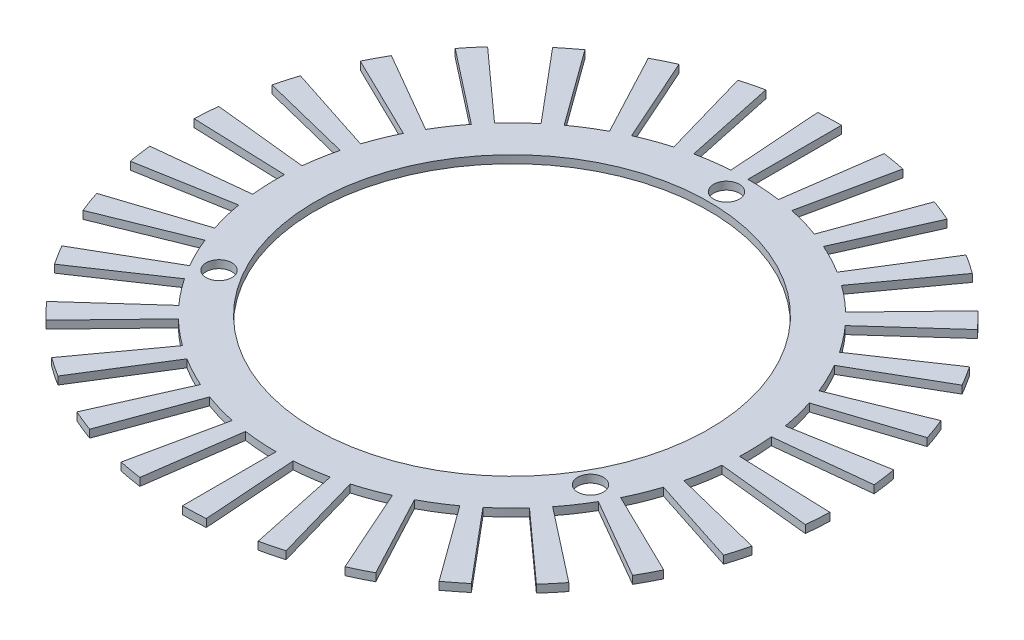
from build123d import *

# Parameters (mm, degrees)
SKETCH1_R           = 30.25
SKETCH1_R_2         = 25.25
EXTRUDE_THIN1_DEPTH = 1
SKETCH2_R           = 1.65
CUT_EXTRUDE3_DEPTH  = 10
BOSS_EXTRUDE1_DEPTH = 1


with BuildPart() as part:
    # Sketch1 → Extrude-Thin1 (new body)
    with BuildSketch(Plane(origin=(0, 0, 0), x_dir=(1, 0, 0), z_dir=(0, 1, 0))):
        Circle(SKETCH1_R)
        Circle(SKETCH1_R_2, mode=Mode.SUBTRACT)
    extrude(amount=-EXTRUDE_THIN1_DEPTH)

    # Sketch2 → Cut-Extrude3 (cut)
    with BuildSketch(Plane(origin=(0, 0, 0), x_dir=(1, 0, 0), z_dir=(0, 1, 0))):
        with Locations((0, 27.5)):
            Circle(SKETCH2_R)
        with Locations((23.815698604, -13.75)):
            Circle(SKETCH2_R)
        with Locations((-23.815698604, -13.75)):
            Circle(SKETCH2_R)
    extrude(amount=-CUT_EXTRUDE3_DEPTH, mode=Mode.SUBTRACT)

    # Sketch5 → Boss-Extrude1 (add)
    with BuildSketch(Plane.XZ.offset(1)):
        with BuildLine():
            Line((0, 42.25), (0, 30.25))
            ThreePointArc((0, 30.25), (1.055709775, 30.231572517), (2.110133331, 30.17631252))
            Line((2.110133331, 30.17631252), (2.947211016, 42.147081123))
            ThreePointArc((2.947211016, 42.147081123), (1.474503736, 42.224262442), (0, 42.25))
        make_face()
        with BuildLine():
            Line((8.784268937, 41.326736131), (6.289328647, 29.588964922))
            ThreePointArc((6.289328647, 29.588964922), (7.318137342, 29.35144572), (8.338030013, 29.078166302))
            Line((8.338030013, 29.078166302), (11.645678283, 40.613306653))
            ThreePointArc((11.645678283, 40.613306653), (10.221200089, 40.994994435), (8.784268937, 41.326736131))
        make_face()
        with BuildLine():
            Line((17.18462317, 38.597295585), (12.303783453, 27.634750094))
            ThreePointArc((12.303783453, 27.634750094), (13.26072719, 27.188519901), (14.201514774, 26.709164684))
            Line((14.201514774, 26.709164684), (19.835173528, 37.304535798))
            ThreePointArc((19.835173528, 37.304535798), (18.521180952, 37.974048456), (17.18462317, 38.597295585))
        make_face()
        with BuildLine():
            Line((24.833926909, 34.180968012), (17.780503882, 24.47276408))
            ThreePointArc((17.780503882, 24.47276408), (18.623759629, 23.837325297), (19.444325193, 23.172844404))
            Line((19.444325193, 23.172844404), (27.157776509, 32.365377722))
            ThreePointArc((27.157776509, 32.365377722), (26.011697333, 33.29345434), (24.833926909, 34.180968012))
        make_face()
        with BuildLine():
            Line((31.397868876, 28.270768119), (22.480130971, 20.241200842))
            ThreePointArc((22.480130971, 20.241200842), (23.172844404, 19.444325193), (23.837325297, 18.623759629))
            Line((23.837325297, 18.623759629), (33.29345434, 26.011697333))
            ThreePointArc((33.29345434, 26.011697333), (32.365377722, 27.157776509), (31.397868876, 28.270768119))
        make_face()
        with BuildLine():
            Line((36.58957331, 21.125), (26.197268464, 15.125))
            ThreePointArc((26.197268464, 15.125), (26.709164684, 14.201514774), (27.188519901, 13.26072719))
            Line((27.188519901, 13.26072719), (37.974048456, 18.521180952))
            ThreePointArc((37.974048456, 18.521180952), (37.304535798, 19.835173528), (36.58957331, 21.125))
        make_face()
        with BuildLine():
            Line((40.182137813, 13.055968012), (28.769459618, 9.34776408))
            ThreePointArc((28.769459618, 9.34776408), (29.078166302, 8.338030013), (29.35144572, 7.318137342))
            Line((29.35144572, 7.318137342), (40.994994435, 10.221200089))
            ThreePointArc((40.994994435, 10.221200089), (40.613306653, 11.645678283), (40.182137813, 13.055968012))
        make_face()
        with BuildLine():
            Line((42.018550079, 4.416327573), (30.084287335, 3.161986014))
            ThreePointArc((30.084287335, 3.161986014), (30.17631252, 2.110133331), (30.231572517, 1.055709775))
            Line((30.231572517, 1.055709775), (42.224262442, 1.474503736))
            ThreePointArc((42.224262442, 1.474503736), (42.147081123, 2.947211016), (42.018550079, 4.416327573))
        make_face()
        with BuildLine():
            Line((42.018550079, -4.416327573), (30.084287335, -3.161986014))
            ThreePointArc((30.084287335, -3.161986014), (29.955609079, -4.209986304), (29.790434529, -5.252857374))
            Line((29.790434529, -5.252857374), (41.608127565, -7.336635506))
            ThreePointArc((41.608127565, -7.336635506), (41.838825904, -5.880063516), (42.018550079, -4.416327573))
        make_face()
        with BuildLine():
            Line((40.182137813, -13.055968012), (28.769459618, -9.34776408))
            ThreePointArc((28.769459618, -9.34776408), (28.425701779, -10.346109336), (28.047311601, -11.331849451))
            Line((28.047311601, -11.331849451), (39.173517855, -15.827128572))
            ThreePointArc((39.173517855, -15.827128572), (39.702013228, -14.450351056), (40.182137813, -13.055968012))
        make_face()
        with BuildLine():
            Line((36.58957331, -21.125), (26.197268464, -15.125))
            ThreePointArc((26.197268464, -15.125), (25.653454909, -16.030057743), (25.07838657, -16.91558533))
            Line((25.07838657, -16.91558533), (35.02683744, -23.625900172))
            ThreePointArc((35.02683744, -23.625900172), (35.830032063, -22.389088914), (36.58957331, -21.125))
        make_face()
        with BuildLine():
            Line((31.397868876, -28.270768119), (22.480130971, -20.241200842))
            ThreePointArc((22.480130971, -20.241200842), (21.76002896, -21.013415706), (21.013415706, -21.76002896))
            Line((21.013415706, -21.76002896), (29.349316152, -30.392106564))
            ThreePointArc((29.349316152, -30.392106564), (30.392106564, -29.349316152), (31.397868876, -28.270768119))
        make_face()
        with BuildLine():
            Line((24.833926909, -34.180968012), (17.780503882, -24.47276408))
            ThreePointArc((17.780503882, -24.47276408), (16.91558533, -25.07838657), (16.030057743, -25.653454909))
            Line((16.030057743, -25.653454909), (22.389088914, -35.830032063))
            ThreePointArc((22.389088914, -35.830032063), (23.625900172, -35.02683744), (24.833926909, -34.180968012))
        make_face()
        with BuildLine():
            Line((17.18462317, -38.597295585), (12.303783453, -27.634750094))
            ThreePointArc((12.303783453, -27.634750094), (11.331849451, -28.047311601), (10.346109336, -28.425701779))
            Line((10.346109336, -28.425701779), (14.450351056, -39.702013228))
            ThreePointArc((14.450351056, -39.702013228), (15.827128572, -39.173517855), (17.18462317, -38.597295585))
        make_face()
        with BuildLine():
            Line((8.784268937, -41.326736131), (6.289328647, -29.588964922))
            ThreePointArc((6.289328647, -29.588964922), (5.252857374, -29.790434529), (4.209986304, -29.955609079))
            Line((4.209986304, -29.955609079), (5.880063516, -41.838825904))
            ThreePointArc((5.880063516, -41.838825904), (7.336635506, -41.608127565), (8.784268937, -41.326736131))
        make_face()
        with BuildLine():
            Line((0, -42.25), (0, -30.25))
            ThreePointArc((0, -30.25), (-1.055709775, -30.231572517), (-2.110133331, -30.17631252))
            Line((-2.110133331, -30.17631252), (-2.947211016, -42.147081123))
            ThreePointArc((-2.947211016, -42.147081123), (-1.474503736, -42.224262442), (0, -42.25))
        make_face()
        with BuildLine():
            Line((-8.784268937, -41.326736131), (-6.289328647, -29.588964922))
            ThreePointArc((-6.289328647, -29.588964922), (-7.318137342, -29.35144572), (-8.338030013, -29.078166302))
            Line((-8.338030013, -29.078166302), (-11.645678283, -40.613306653))
            ThreePointArc((-11.645678283, -40.613306653), (-10.221200089, -40.994994435), (-8.784268937, -41.326736131))
        make_face()
        with BuildLine():
            Line((-17.18462317, -38.597295585), (-12.303783453, -27.634750094))
            ThreePointArc((-12.303783453, -27.634750094), (-13.26072719, -27.188519901), (-14.201514774, -26.709164684))
            Line((-14.201514774, -26.709164684), (-19.835173528, -37.304535798))
            ThreePointArc((-19.835173528, -37.304535798), (-18.521180952, -37.974048456), (-17.18462317, -38.597295585))
        make_face()
        with BuildLine():
            Line((-24.833926909, -34.180968012), (-17.780503882, -24.47276408))
            ThreePointArc((-17.780503882, -24.47276408), (-18.623759629, -23.837325297), (-19.444325193, -23.172844404))
            Line((-19.444325193, -23.172844404), (-27.157776509, -32.365377722))
            ThreePointArc((-27.157776509, -32.365377722), (-26.011697333, -33.29345434), (-24.833926909, -34.180968012))
        make_face()
        with BuildLine():
            Line((-31.397868876, -28.270768119), (-22.480130971, -20.241200842))
            ThreePointArc((-22.480130971, -20.241200842), (-23.172844404, -19.444325193), (-23.837325297, -18.623759629))
            Line((-23.837325297, -18.623759629), (-33.29345434, -26.011697333))
            ThreePointArc((-33.29345434, -26.011697333), (-32.365377722, -27.157776509), (-31.397868876, -28.270768119))
        make_face()
        with BuildLine():
            Line((-36.58957331, -21.125), (-26.197268464, -15.125))
            ThreePointArc((-26.197268464, -15.125), (-26.709164684, -14.201514774), (-27.188519901, -13.26072719))
            Line((-27.188519901, -13.26072719), (-37.974048456, -18.521180952))
            ThreePointArc((-37.974048456, -18.521180952), (-37.304535798, -19.835173528), (-36.58957331, -21.125))
        make_face()
        with BuildLine():
            Line((-40.182137813, -13.055968012), (-28.769459618, -9.34776408))
            ThreePointArc((-28.769459618, -9.34776408), (-29.078166302, -8.338030013), (-29.35144572, -7.318137342))
            Line((-29.35144572, -7.318137342), (-40.994994435, -10.221200089))
            ThreePointArc((-40.994994435, -10.221200089), (-40.613306653, -11.645678283), (-40.182137813, -13.055968012))
        make_face()
        with BuildLine():
            Line((-42.018550079, -4.416327573), (-30.084287335, -3.161986014))
            ThreePointArc((-30.084287335, -3.161986014), (-30.17631252, -2.110133331), (-30.231572517, -1.055709775))
            Line((-30.231572517, -1.055709775), (-42.224262442, -1.474503736))
            ThreePointArc((-42.224262442, -1.474503736), (-42.147081123, -2.947211016), (-42.018550079, -4.416327573))
        make_face()
        with BuildLine():
            Line((-42.018550079, 4.416327573), (-30.084287335, 3.161986014))
            ThreePointArc((-30.084287335, 3.161986014), (-29.955609079, 4.209986304), (-29.790434529, 5.252857374))
            Line((-29.790434529, 5.252857374), (-41.608127565, 7.336635506))
            ThreePointArc((-41.608127565, 7.336635506), (-41.838825904, 5.880063516), (-42.018550079, 4.416327573))
        make_face()
        with BuildLine():
            Line((-40.182137813, 13.055968012), (-28.769459618, 9.34776408))
            ThreePointArc((-28.769459618, 9.34776408), (-28.425701779, 10.346109336), (-28.047311601, 11.331849451))
            Line((-28.047311601, 11.331849451), (-39.173517855, 15.827128572))
            ThreePointArc((-39.173517855, 15.827128572), (-39.702013228, 14.450351056), (-40.182137813, 13.055968012))
        make_face()
        with BuildLine():
            Line((-36.58957331, 21.125), (-26.197268464, 15.125))
            ThreePointArc((-26.197268464, 15.125), (-25.653454909, 16.030057743), (-25.07838657, 16.91558533))
            Line((-25.07838657, 16.91558533), (-35.02683744, 23.625900172))
            ThreePointArc((-35.02683744, 23.625900172), (-35.830032063, 22.389088914), (-36.58957331, 21.125))
        make_face()
        with BuildLine():
            Line((-31.397868876, 28.270768119), (-22.480130971, 20.241200842))
            ThreePointArc((-22.480130971, 20.241200842), (-21.76002896, 21.013415706), (-21.013415706, 21.76002896))
            Line((-21.013415706, 21.76002896), (-29.349316152, 30.392106564))
            ThreePointArc((-29.349316152, 30.392106564), (-30.392106564, 29.349316152), (-31.397868876, 28.270768119))
        make_face()
        with BuildLine():
            Line((-24.833926909, 34.180968012), (-17.780503882, 24.47276408))
            ThreePointArc((-17.780503882, 24.47276408), (-16.91558533, 25.07838657), (-16.030057743, 25.653454909))
            Line((-16.030057743, 25.653454909), (-22.389088914, 35.830032063))
            ThreePointArc((-22.389088914, 35.830032063), (-23.625900172, 35.02683744), (-24.833926909, 34.180968012))
        make_face()
        with BuildLine():
            Line((-17.18462317, 38.597295585), (-12.303783453, 27.634750094))
            ThreePointArc((-12.303783453, 27.634750094), (-11.331849451, 28.047311601), (-10.346109336, 28.425701779))
            Line((-10.346109336, 28.425701779), (-14.450351056, 39.702013228))
            ThreePointArc((-14.450351056, 39.702013228), (-15.827128572, 39.173517855), (-17.18462317, 38.597295585))
        make_face()
        with BuildLine():
            Line((-8.784268937, 41.326736131), (-6.289328647, 29.588964922))
            ThreePointArc((-6.289328647, 29.588964922), (-5.252857374, 29.790434529), (-4.209986304, 29.955609079))
            Line((-4.209986304, 29.955609079), (-5.880063516, 41.838825904))
            ThreePointArc((-5.880063516, 41.838825904), (-7.336635506, 41.608127565), (-8.784268937, 41.326736131))
        make_face()
    extrude(amount=-BOSS_EXTRUDE1_DEPTH)


solid = part.part
